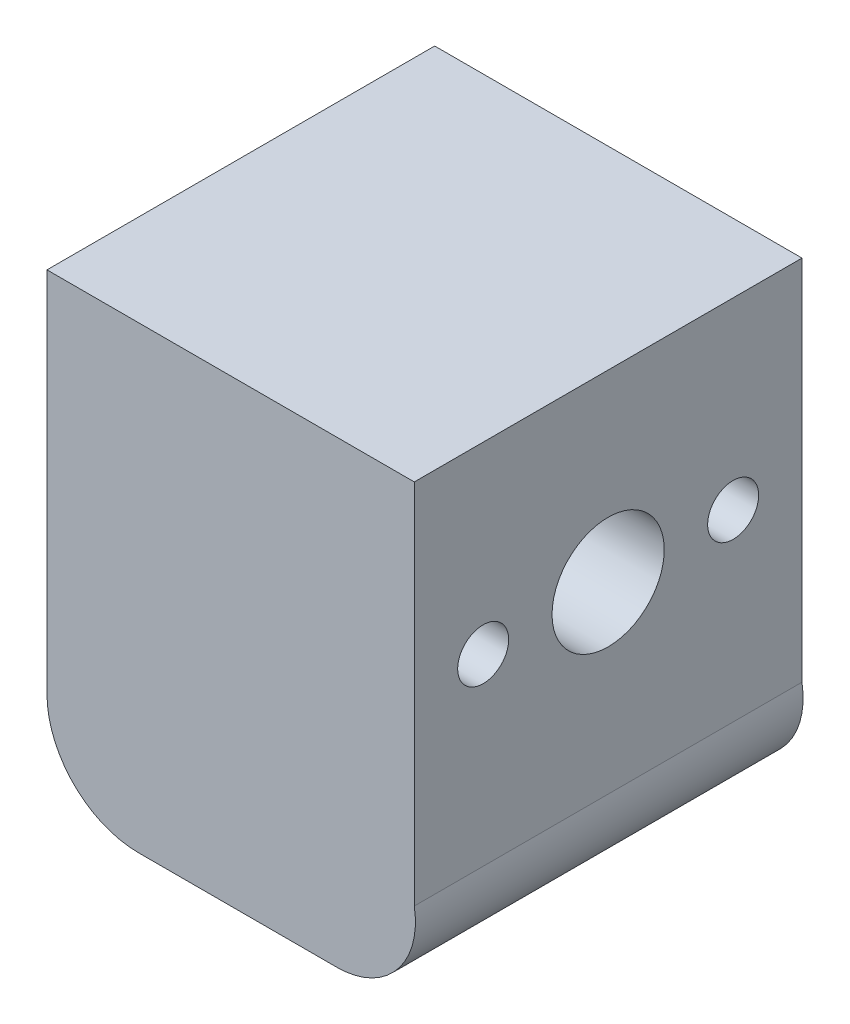
from build123d import *

# Parameters (mm, degrees)
BOSS_EXTRUDE1_DEPTH = 9.5
SKETCH3_R           = 2.75
SKETCH3_R_2         = 1.25
CUT_EXTRUDE1_DEPTH  = 19.054661658


with BuildPart() as part:
    # Sketch2 → Boss-Extrude1 (new body, symmetric)
    with BuildSketch(Plane.XY):
        with BuildLine():
            Line((-37.204062484, 20.661621188), (-37.204062484, 2.661621188))
            ThreePointArc((-37.204062484, 2.661621188), (-35.886988122, -0.518077598), (-32.707289335, -1.83515196))
            Line((-32.707289335, -1.83515196), (-22.999692171, -1.83515196))
            ThreePointArc((-22.999692171, -1.83515196), (-20.057423766, -0.468366217), (-19.204062484, 2.661621188))
            Line((-19.204062484, 2.661621188), (-19.204062484, 20.661621188))
            Line((-19.204062484, 20.661621188), (-37.204062484, 20.661621188))
        make_face()
    extrude(amount=BOSS_EXTRUDE1_DEPTH, both=True)

    # Sketch3 → Cut-Extrude1 (cut, through all)
    with BuildSketch(Plane.ZY.offset(37.204062484)):
        with Locations((0, 11.661621188)):
            Circle(SKETCH3_R)
        with Locations((6.125, 11.661621188)):
            Circle(SKETCH3_R_2)
        with Locations((-6.125, 11.661621188)):
            Circle(SKETCH3_R_2)
    extrude(amount=-CUT_EXTRUDE1_DEPTH, mode=Mode.SUBTRACT)


solid = part.part
